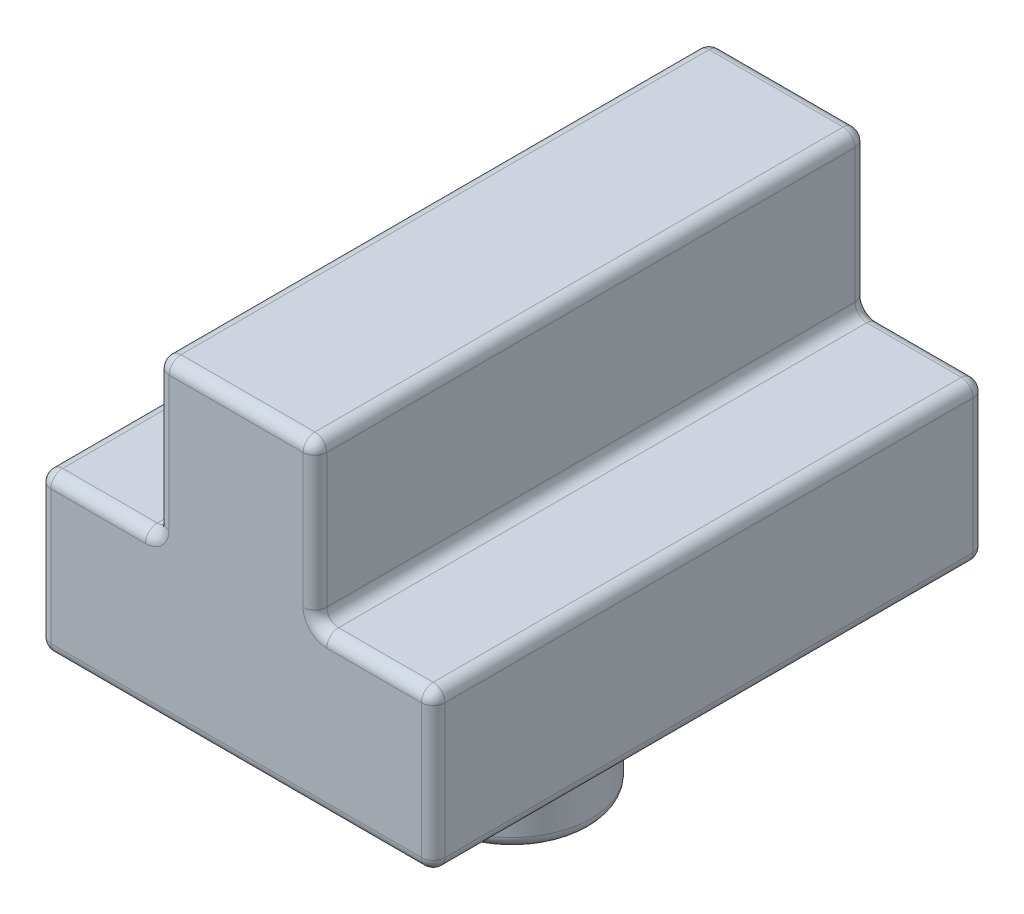
from build123d import *

# Parameters (mm, degrees)
BOSS_EXTRUDE1_DEPTH = 35
SKETCH2_R           = 10
BOSS_EXTRUDE2_DEPTH = 20
FILLET1_R           = 1.5
FILLET2_R           = 1.5


with BuildPart() as part:
    # Sketch1 → Boss-Extrude1 (new body, symmetric)
    with BuildSketch(Plane.XY):
        Polygon((0, 0), (0, 20), (15, 20), (15, 40), (35, 40), (35, 20), (50, 20), (50, 0), align=None)
    extrude(amount=BOSS_EXTRUDE1_DEPTH, both=True)

    # Sketch2 → Boss-Extrude2 (add)
    with BuildSketch(Plane(origin=(0, 0, 0), x_dir=(-1, 0, 0), z_dir=(0, -1, 0))):
        with Locations((-25, 0)):
            Circle(SKETCH2_R)
    extrude(amount=BOSS_EXTRUDE2_DEPTH)

    # Fillet1
    fillet1_edges = [part.edges().sort_by_distance(p)[0] for p in [
        (35, 30, -35),
        (42.5, 20, -35),
        (50, 10, -35),
        (25, 0, -35),
        (42.5, 20, 35),
        (0, 0, 0),
        (0, 20, 0),
        (15, 20, 0),
        (15, 40, 0),
        (35, 40, 0),
        (35, 20, 0),
        (50, 20, 0),
        (50, 0, 0),
        (35, 30, 35),
        (25, 40, 35),
        (35, 0, 0),
        (15, 30, 35),
        (7.5, 20, 35),
        (0, 10, 35),
        (25, 0, 35),
        (0, 10, -35),
        (50, 10, 35),
        (7.5, 20, -35),
        (15, 30, -35),
        (25, 40, -35),
    ]]
    fillet(fillet1_edges, radius=FILLET1_R)

    # Fillet2
    fillet2_edges = [part.edges().sort_by_distance(p)[0] for p in [
        (35, -20, 0),
    ]]
    fillet(fillet2_edges, radius=FILLET2_R)


solid = part.part
